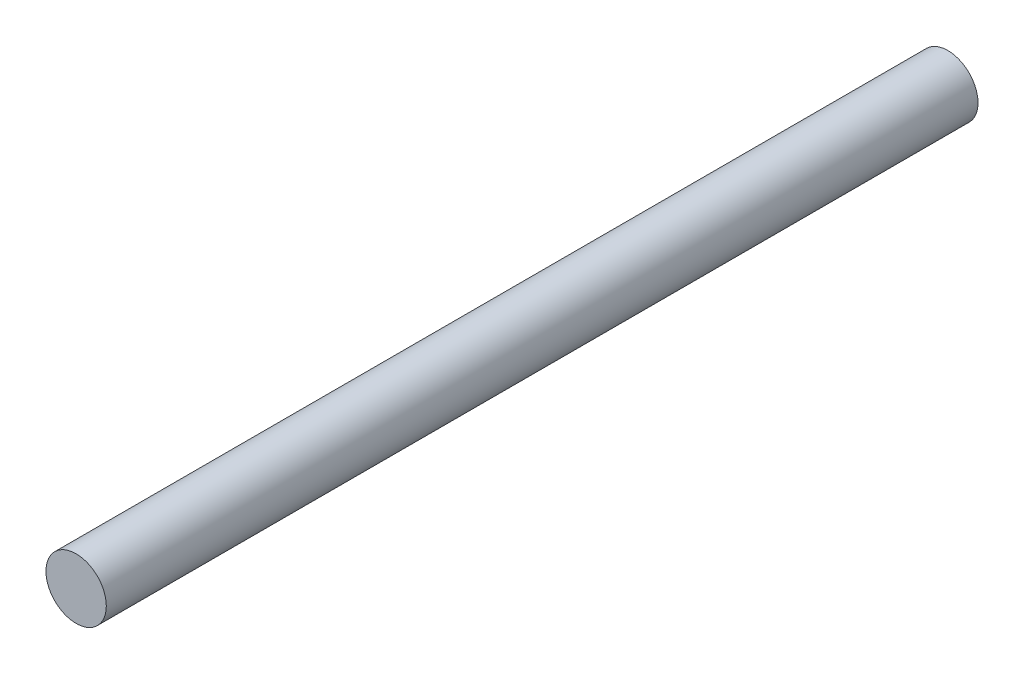
from build123d import *

# Parameters (mm, degrees)
SKETCH1_R           = 1.143
BOSS_EXTRUDE1_DEPTH = 33.02


with BuildPart() as part:
    # Sketch1 → Boss-Extrude1 (new body)
    with BuildSketch(Plane.XY):
        Circle(SKETCH1_R)
    extrude(amount=BOSS_EXTRUDE1_DEPTH)


solid = part.part
